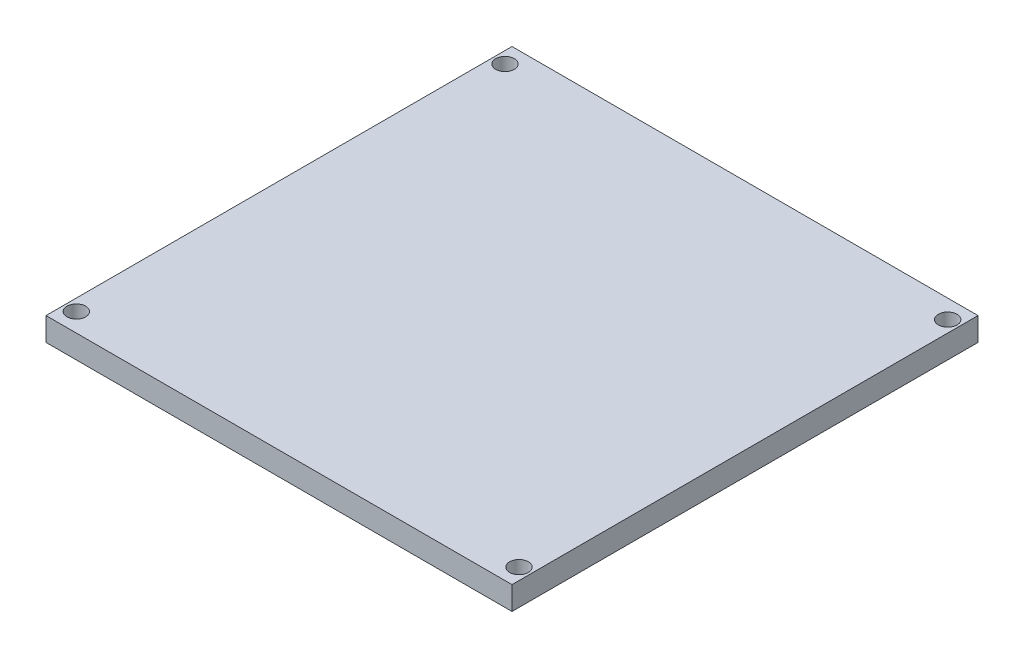
from build123d import *

# Parameters (mm, degrees)
SKETCH1_W                 = 100
SKETCH1_H                 = 100
BOSS_EXTRUDE1_DEPTH       = 5
F_4_0MM_DOWEL_HOLE1_D     = 4
F_4_0MM_DOWEL_HOLE1_DEPTH = 5


with BuildPart() as part:
    # Sketch1 → Boss-Extrude1 (new body)
    with BuildSketch(Plane(origin=(0, 0, 0), x_dir=(1, 0, 0), z_dir=(0, 1, 0))):
        Rectangle(SKETCH1_W, SKETCH1_H)
    extrude(amount=BOSS_EXTRUDE1_DEPTH)

    # Ø4.0mm Dowel Hole1
    with Locations(Plane(origin=(-47.5, 5, -46), x_dir=(0, 0, 1), z_dir=(0, 1, 0))):
        with Locations((0, 0), (0, 95), (92, 95), (92, 0)):
            Hole(F_4_0MM_DOWEL_HOLE1_D / 2, depth=F_4_0MM_DOWEL_HOLE1_DEPTH)


solid = part.part
